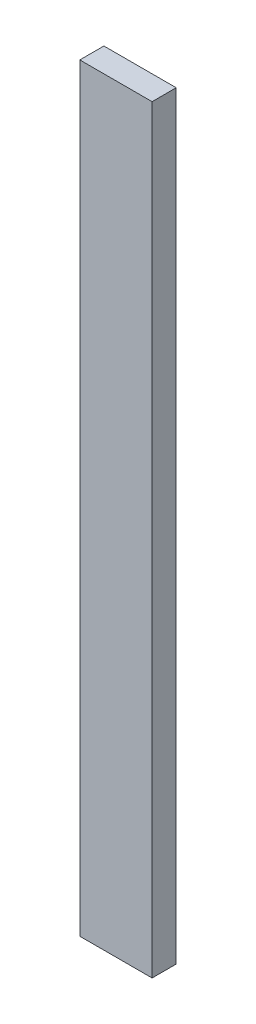
from build123d import *

# Parameters (mm, degrees)
SKETCH1_W           = 38.1
SKETCH1_H           = 12.7
BOSS_EXTRUDE1_DEPTH = 400


with BuildPart() as part:
    # Sketch1 → Boss-Extrude1 (new body)
    with BuildSketch(Plane(origin=(0, 0, 0), x_dir=(1, 0, 0), z_dir=(0, 1, 0))):
        with Locations((19.05, 6.35)):
            Rectangle(SKETCH1_W, SKETCH1_H)
    extrude(amount=BOSS_EXTRUDE1_DEPTH)


solid = part.part
